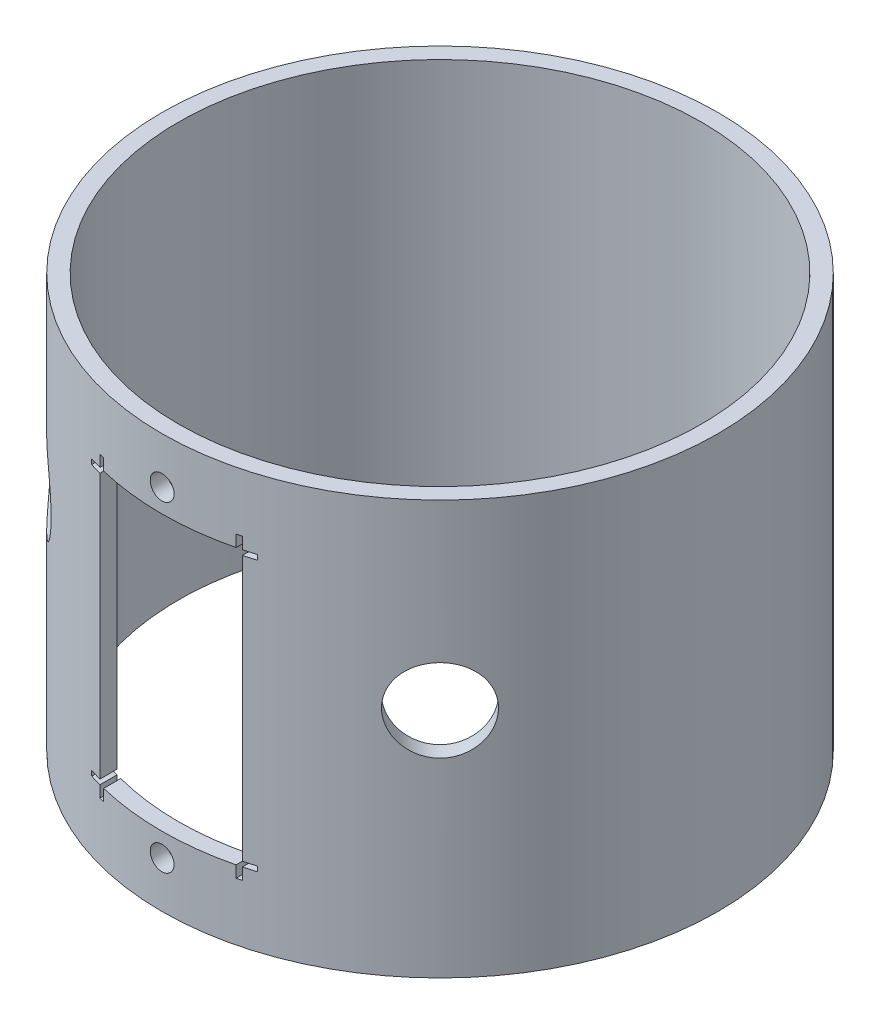
from build123d import *

# Parameters (mm, degrees)
SKETCH1_R           = 42.672
BOSS_EXTRUDE1_DEPTH = 63.5
SKETCH2_R           = 40.132
CUT_EXTRUDE1_DEPTH  = 88.601650487
SKETCH3_R           = 1.8288
CUT_EXTRUDE2_DEPTH  = 88.601650487
SKETCH4_R           = 6.35
CUT_EXTRUDE3_DEPTH  = 88.601650665
SKETCH5_R           = 6.35
CUT_EXTRUDE4_DEPTH  = 88.601650665


with BuildPart() as part:
    # Sketch1 → Boss-Extrude1 (new body)
    with BuildSketch(Plane(origin=(0, 0, 0), x_dir=(1, 0, 0), z_dir=(0, 1, 0))):
        Circle(SKETCH1_R)
    extrude(amount=BOSS_EXTRUDE1_DEPTH)

    # Sketch2 → Cut-Extrude1 (cut, through all)
    with BuildSketch(Plane(origin=(0, 0, 0), x_dir=(1, 0, 0), z_dir=(0, 1, 0))):
        Circle(SKETCH2_R)
    extrude(amount=CUT_EXTRUDE1_DEPTH, mode=Mode.SUBTRACT)

    # Sketch3 → Cut-Extrude2 (cut, through all)
    with BuildSketch(Plane.XY):
        Polygon((-12.7, 52.832), (-12.7, 52.07), (-10.922, 52.07), (-10.922, 11.43), (-12.7, 11.43), (-12.7, 10.668), (-10.922, 10.668), (-10.922, 8.89), (-10.16, 8.89), (-10.16, 10.668), (10.16, 10.668), (10.16, 8.89), (10.922, 8.89), (10.922, 10.668), (12.7, 10.668), (12.7, 11.43), (10.922, 11.43), (10.922, 52.07), (12.7, 52.07), (12.7, 52.832), (10.922, 52.832), (10.922, 54.61), (10.16, 54.61), (10.16, 52.832), (-10.16, 52.832), (-10.16, 54.61), (-10.922, 54.61), (-10.922, 52.832), align=None)
        with Locations((0, 56.388)):
            Circle(SKETCH3_R)
        with Locations((0, 7.112)):
            Circle(SKETCH3_R)
    extrude(amount=CUT_EXTRUDE2_DEPTH, mode=Mode.SUBTRACT)

    # Sketch4 → Cut-Extrude3 (cut, through all)
    with BuildSketch(Plane(origin=(0, 0, 0), x_dir=(0, -1, 0), z_dir=(-0.7071067811865488, 0, 0.7071067811865464))):
        with Locations((-35.56, 0)):
            Circle(SKETCH4_R)
    extrude(amount=CUT_EXTRUDE3_DEPTH, mode=Mode.SUBTRACT)

    # Sketch5 → Cut-Extrude4 (cut, through all)
    with BuildSketch(Plane(origin=(0, 0, 0), x_dir=(0, -1, 0), z_dir=(-0.7071067811865464, 0, -0.7071067811865488))):
        with Locations((-35.56, 0)):
            Circle(SKETCH5_R)
    extrude(amount=-CUT_EXTRUDE4_DEPTH, mode=Mode.SUBTRACT)


solid = part.part
